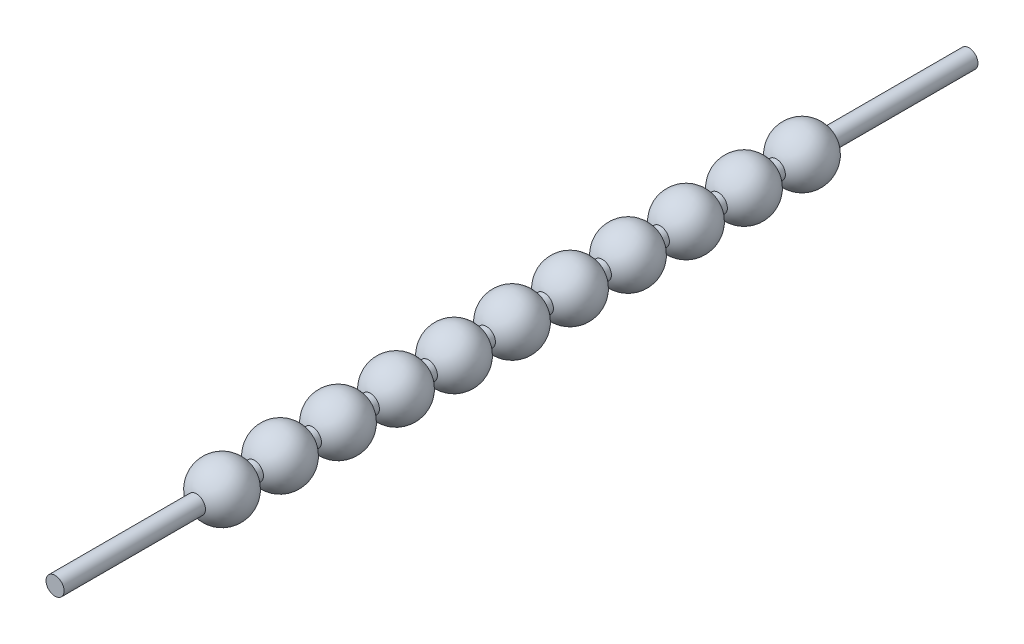
from build123d import *


with BuildPart() as part:
    # 草图1 one side → 旋转1 (revolve)
    with BuildSketch(Plane(origin=(0, 0, 0), x_dir=(0, 0, -1), z_dir=(1, 0, 0))):
        with BuildLine():
            Line((10.428552104, 0.5), (10.056979229, 0.5))
            ThreePointArc((10.056979229, 0.5), (8.642765666, 1.5), (7.228552104, 0.5))
            Line((7.228552104, 0.5), (-0.571447896, 0.5))
            Line((-0.571447896, 0.5), (-0.571447896, 0))
            Line((-0.571447896, 0), (7.142765666, 0))
            Line((7.142765666, 0), (10.142765666, 0))
            Line((10.142765666, 0), (10.342765666, 0))
            Line((10.342765666, 0), (13.342765666, 0))
            Line((13.342765666, 0), (13.542765666, 0))
            Line((13.542765666, 0), (16.542765666, 0))
            Line((16.542765666, 0), (16.742765666, 0))
            Line((16.742765666, 0), (19.742765666, 0))
            Line((19.742765666, 0), (19.942765666, 0))
            Line((19.942765666, 0), (22.942765666, 0))
            Line((22.942765666, 0), (23.142765666, 0))
            Line((23.142765666, 0), (26.142765666, 0))
            Line((26.142765666, 0), (26.342765666, 0))
            Line((26.342765666, 0), (29.342765666, 0))
            Line((29.342765666, 0), (29.542765666, 0))
            Line((29.542765666, 0), (32.542765666, 0))
            Line((32.542765666, 0), (32.742765666, 0))
            Line((32.742765666, 0), (35.742765666, 0))
            Line((35.742765666, 0), (35.942765666, 0))
            Line((35.942765666, 0), (38.942765666, 0))
            Line((38.942765666, 0), (39.142765666, 0))
            Line((39.142765666, 0), (42.142765666, 0))
            Line((42.142765666, 0), (49.856979229, 0))
            Line((49.856979229, 0), (49.856979229, 0.5))
            Line((49.856979229, 0.5), (42.056979229, 0.5))
            ThreePointArc((42.056979229, 0.5), (40.642765666, 1.5), (39.228552104, 0.5))
            Line((39.228552104, 0.5), (38.856979229, 0.5))
            ThreePointArc((38.856979229, 0.5), (37.442765666, 1.5), (36.028552104, 0.5))
            Line((36.028552104, 0.5), (35.656979229, 0.5))
            ThreePointArc((35.656979229, 0.5), (34.242765666, 1.5), (32.828552104, 0.5))
            Line((32.828552104, 0.5), (32.456979229, 0.5))
            ThreePointArc((32.456979229, 0.5), (31.042765666, 1.5), (29.628552104, 0.5))
            Line((29.628552104, 0.5), (29.256979229, 0.5))
            ThreePointArc((29.256979229, 0.5), (27.842765666, 1.5), (26.428552104, 0.5))
            Line((26.428552104, 0.5), (26.056979229, 0.5))
            ThreePointArc((26.056979229, 0.5), (24.642765666, 1.5), (23.228552104, 0.5))
            Line((23.228552104, 0.5), (22.856979229, 0.5))
            ThreePointArc((22.856979229, 0.5), (21.442765666, 1.5), (20.028552104, 0.5))
            Line((20.028552104, 0.5), (19.656979229, 0.5))
            ThreePointArc((19.656979229, 0.5), (18.242765666, 1.5), (16.828552104, 0.5))
            Line((16.828552104, 0.5), (16.456979229, 0.5))
            ThreePointArc((16.456979229, 0.5), (15.042765666, 1.5), (13.628552104, 0.5))
            Line((13.628552104, 0.5), (13.256979229, 0.5))
            ThreePointArc((13.256979229, 0.5), (11.842765666, 1.5), (10.428552104, 0.5))
        make_face()
    revolve(axis=Axis((0, 0, 0.652504335), (0, 0, -1)))


solid = part.part
